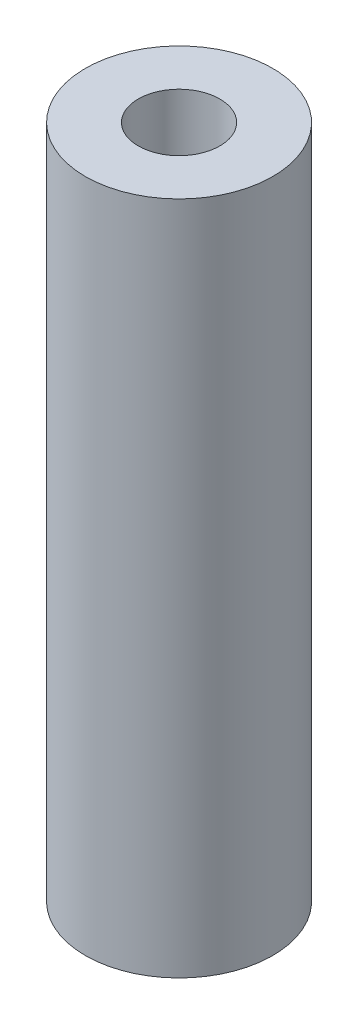
from build123d import *

# Parameters (mm, degrees)
CROQUIS1_R              = 5
SALIENTE_EXTRUIR1_DEPTH = 36
CROQUIS2_R              = 2.175
CORTAR_EXTRUIR1_DEPTH   = 36


with BuildPart() as part:
    # Croquis1 → Saliente-Extruir1 (new body)
    with BuildSketch(Plane(origin=(0, 0, 0), x_dir=(1, 0, 0), z_dir=(0, 1, 0))):
        Circle(CROQUIS1_R)
    extrude(amount=SALIENTE_EXTRUIR1_DEPTH)

    # Croquis2 → Cortar-Extruir1 (cut)
    with BuildSketch(Plane(origin=(0, 36, 0), x_dir=(1, 0, 0), z_dir=(0, 1, 0))):
        Circle(CROQUIS2_R)
    extrude(amount=-CORTAR_EXTRUIR1_DEPTH, mode=Mode.SUBTRACT)


solid = part.part
